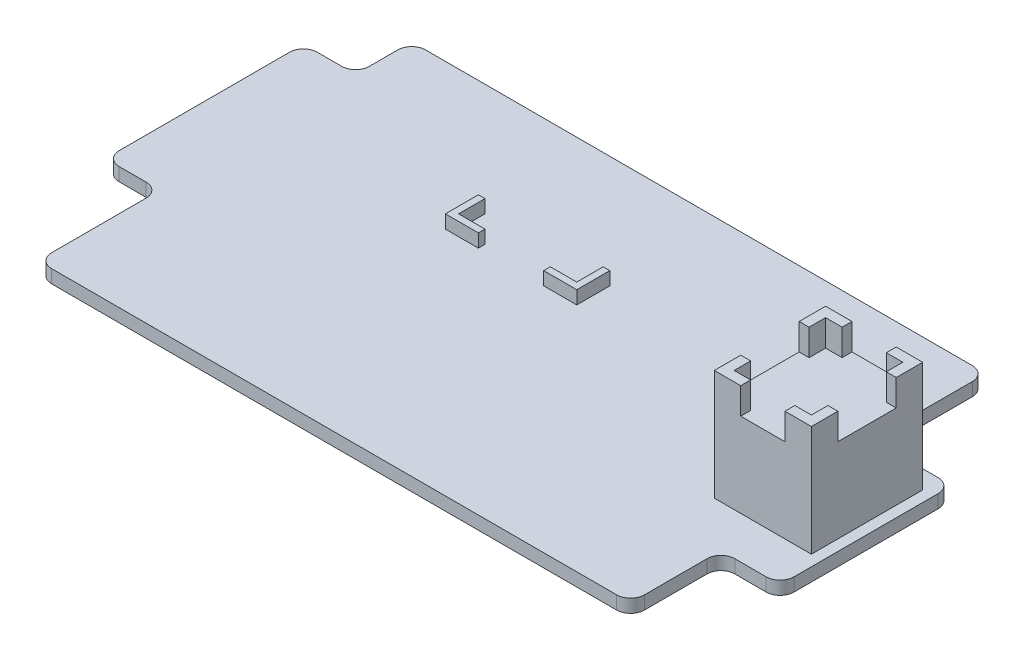
from build123d import *

# Parameters (mm, degrees)
BOSS_EXTRUDE1_DEPTH = 2
BOSS_EXTRUDE2_DEPTH = 2
SKETCH3_W           = 14.7
SKETCH3_H           = 16.85
BOSS_EXTRUDE3_DEPTH = 12.75
BOSS_EXTRUDE4_DEPTH = 4


with BuildPart() as part:
    # Sketch1 → Boss-Extrude1 (new body)
    with BuildSketch(Plane(origin=(0, 0, 0), x_dir=(1, 0, 0), z_dir=(0, 1, 0))):
        with BuildLine():
            Line((-14.340002267, 86.923975611), (-97.140002267, 86.923975611))
            ThreePointArc((-97.140002267, 86.923975611), (-98.624926507, 86.308899852), (-99.240002267, 84.823975611))
            Line((-99.240002267, 84.823975611), (-99.240002267, 80.522464507))
            ThreePointArc((-99.240002267, 80.522464507), (-99.855078026, 79.037540266), (-101.340002267, 78.422464507))
            Line((-101.340002267, 78.422464507), (-105.03337779, 78.422464507))
            ThreePointArc((-105.03337779, 78.422464507), (-106.51830203, 77.807388747), (-107.13337779, 76.322464507))
            Line((-107.13337779, 76.322464507), (-107.13337779, 50.522464507))
            ThreePointArc((-107.13337779, 50.522464507), (-106.51830203, 49.037540266), (-105.03337779, 48.422464507))
            Line((-105.03337779, 48.422464507), (-100.956274126, 48.422464507))
            ThreePointArc((-100.956274126, 48.422464507), (-99.471349885, 47.807388747), (-98.856274126, 46.322464507))
            Line((-98.856274126, 46.322464507), (-98.856274126, 32.023975611))
            ThreePointArc((-98.856274126, 32.023975611), (-98.241198366, 30.539051371), (-96.756274126, 29.923975611))
            Line((-96.756274126, 29.923975611), (-11.195092997, 29.923975611))
            ThreePointArc((-11.195092997, 29.923975611), (-9.710168757, 30.539051371), (-9.095092997, 32.023975611))
            Line((-9.095092997, 32.023975611), (-9.095092997, 41.509498791))
            ThreePointArc((-9.095092997, 41.509498791), (-8.480017238, 42.994423032), (-6.995092997, 43.609498791))
            Line((-6.995092997, 43.609498791), (-2.23337779, 43.609498791))
            ThreePointArc((-2.23337779, 43.609498791), (-0.748453549, 44.224574551), (-0.13337779, 45.709498791))
            Line((-0.13337779, 45.709498791), (-0.13337779, 67.540883484))
            ThreePointArc((-0.13337779, 67.540883484), (-0.748453549, 69.025807724), (-2.23337779, 69.640883484))
            Line((-2.23337779, 69.640883484), (-10.140002267, 69.640883484))
            ThreePointArc((-10.140002267, 69.640883484), (-11.624926507, 70.255959243), (-12.240002267, 71.740883484))
            Line((-12.240002267, 71.740883484), (-12.240002267, 84.823975611))
            ThreePointArc((-12.240002267, 84.823975611), (-12.855078026, 86.308899852), (-14.340002267, 86.923975611))
        make_face()
    extrude(amount=BOSS_EXTRUDE1_DEPTH)

    # Sketch2 → Boss-Extrude2 (add)
    with BuildSketch(Plane(origin=(0, 2, 0), x_dir=(1, 0, 0), z_dir=(0, 1, 0))):
        Polygon((-52.240002267, 64.923975611), (-57.240002267, 64.923975611), (-57.240002267, 65.923975611), (-53.240002267, 65.923975611), (-53.240002267, 69.923975611), (-52.240002267, 69.923975611), align=None)
        Polygon((-72.140002267, 64.923975611), (-67.140002267, 64.923975611), (-67.140002267, 65.923975611), (-71.140002267, 65.923975611), (-71.140002267, 69.923975611), (-72.140002267, 69.923975611), align=None)
    extrude(amount=BOSS_EXTRUDE2_DEPTH)

    # Sketch3 → Boss-Extrude3 (add)
    with BuildSketch(Plane(origin=(0, 2, 0), x_dir=(1, 0, 0), z_dir=(0, 1, 0))):
        with Locations((-9.13337779, 58.423975611)):
            Rectangle(SKETCH3_W, SKETCH3_H)
    extrude(amount=BOSS_EXTRUDE3_DEPTH)

    # Sketch4 → Boss-Extrude4 (add)
    with BuildSketch(Plane(origin=(0, 14.75, 0), x_dir=(1, 0, 0), z_dir=(0, 1, 0))):
        Polygon((-1.78337779, 49.998975611), (-5.78337779, 49.998975611), (-5.78337779, 51.498975611), (-3.28337779, 51.498975611), (-3.28337779, 53.998975611), (-1.78337779, 53.998975611), align=None)
        Polygon((-1.78337779, 66.848975611), (-5.78337779, 66.848975611), (-5.78337779, 65.348975611), (-3.28337779, 65.348975611), (-3.28337779, 62.848975611), (-1.78337779, 62.848975611), align=None)
        Polygon((-16.48337779, 49.998975611), (-16.48337779, 53.998975611), (-14.98337779, 53.998975611), (-14.98337779, 51.498975611), (-12.48337779, 51.498975611), (-12.48337779, 49.998975611), align=None)
        Polygon((-14.98337779, 62.848975611), (-16.48337779, 62.848975611), (-16.48337779, 66.848975611), (-12.48337779, 66.848975611), (-12.48337779, 65.348975611), (-14.98337779, 65.348975611), align=None)
    extrude(amount=BOSS_EXTRUDE4_DEPTH)


solid = part.part
